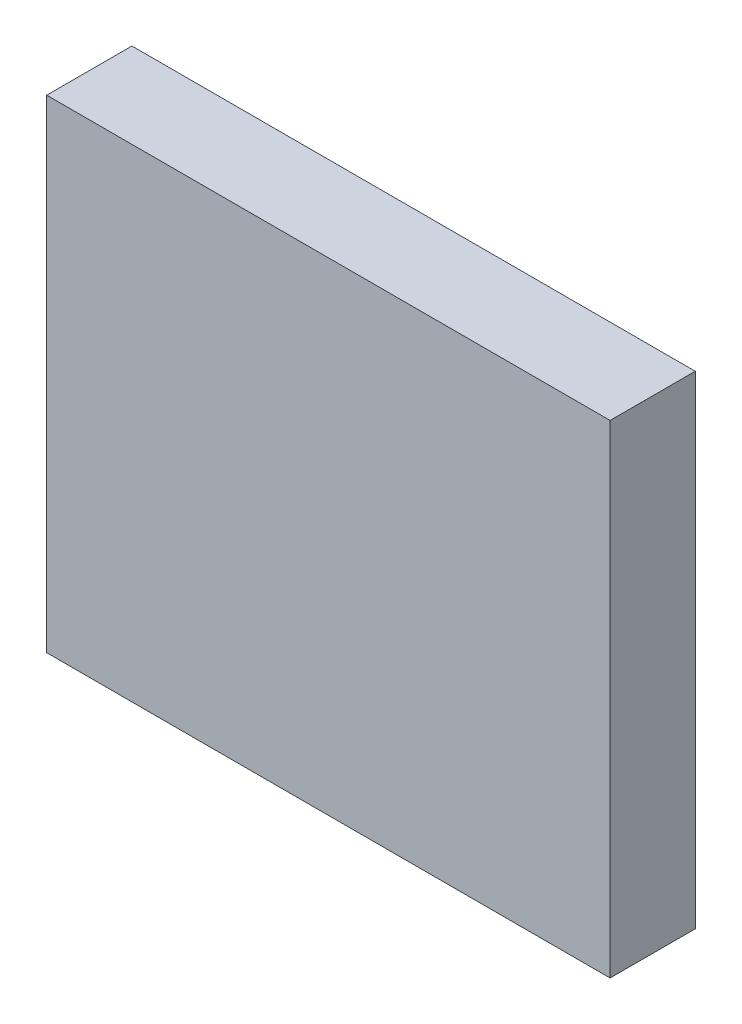
from build123d import *

# Parameters (mm, degrees)
SKETCH1_W           = 21
SKETCH1_H           = 18
BOSS_EXTRUDE1_DEPTH = 3.175


with BuildPart() as part:
    # Sketch1 → Boss-Extrude1 (new body)
    with BuildSketch(Plane.XY):
        with Locations((10.5, 9)):
            Rectangle(SKETCH1_W, SKETCH1_H)
    extrude(amount=BOSS_EXTRUDE1_DEPTH)


solid = part.part
